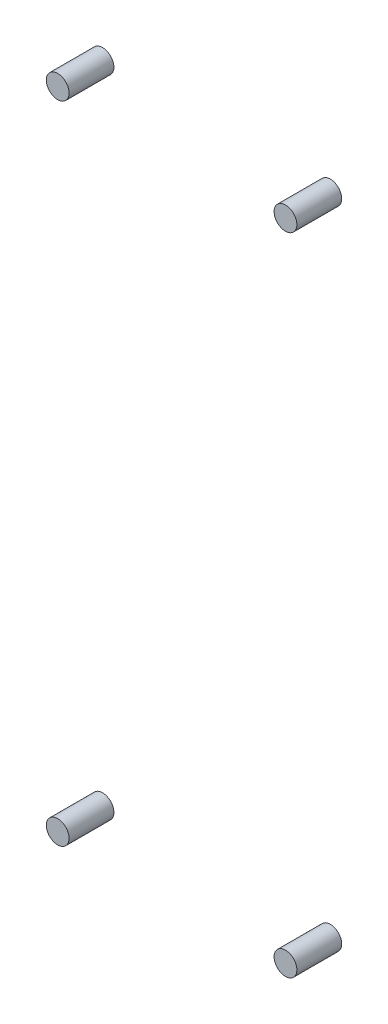
from build123d import *

# Parameters (mm, degrees)
SKETCH2_R             = 0.762
BOSS_EXTRUDE2_DEPTH   = 3
BOSS_EXTRUDE2_2_DEPTH = 3
BOSS_EXTRUDE2_3_DEPTH = 3
BOSS_EXTRUDE2_4_DEPTH = 3


with BuildPart() as part:
    # Sketch2 → Boss-Extrude2 (new body)
    with BuildSketch(Plane.XY):
        with Locations((-7.62, 21.59)):
            Circle(SKETCH2_R)
    extrude(amount=BOSS_EXTRUDE2_DEPTH)


with BuildPart() as body_2:
    # Sketch2 → Boss-Extrude2 2 (new body)
    with BuildSketch(Plane.XY):
        with Locations((7.62, 21.59)):
            Circle(SKETCH2_R)
    extrude(amount=BOSS_EXTRUDE2_2_DEPTH)


with BuildPart() as body_3:
    # Sketch2 → Boss-Extrude2 3 (new body)
    with BuildSketch(Plane.XY):
        with Locations((7.62, -21.59)):
            Circle(SKETCH2_R)
    extrude(amount=BOSS_EXTRUDE2_3_DEPTH)


with BuildPart() as body_4:
    # Sketch2 → Boss-Extrude2 4 (new body)
    with BuildSketch(Plane.XY):
        with Locations((-7.62, -21.59)):
            Circle(SKETCH2_R)
    extrude(amount=BOSS_EXTRUDE2_4_DEPTH)


solid = Compound([part.part, body_2.part, body_3.part, body_4.part])
